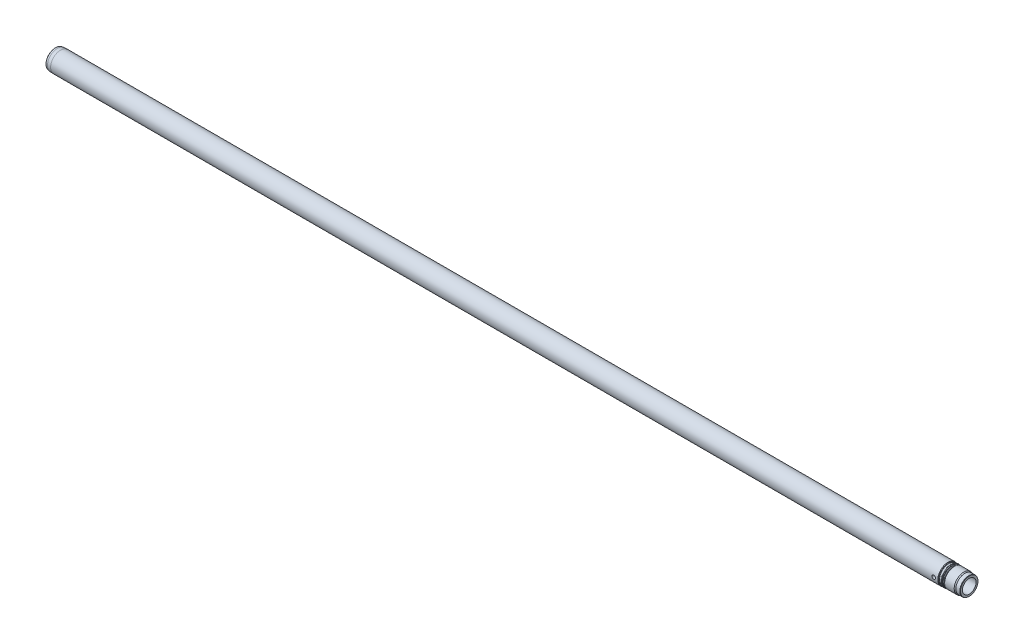
from build123d import *

# Parameters (mm, degrees)
SKETCH2_R          = 4.5
CUT_EXTRUDE1_DEPTH = 50


with BuildPart() as part:
    # Sketch1 → Base-Revolve (revolve)
    with BuildSketch(Plane.XY):
        with BuildLine():
            Line((0, 21), (0, 23.5))
            Line((0, 23.5), (0.5, 24))
            Line((0.5, 24), (5, 24))
            Line((5, 24), (5, 24.75))
            Line((5, 24.75), (13, 24.75))
            Line((13, 24.75), (13, 25))
            Line((13, 25), (2230.5, 25))
            Line((2230.5, 25), (2232, 24.133974596))
            Line((2232, 24.133974596), (2232, 23.8))
            ThreePointArc((2232, 23.8), (2232.234314575, 23.234314575), (2232.8, 23))
            Line((2232.8, 23), (2237.2, 23))
            ThreePointArc((2237.2, 23), (2237.765685425, 23.234314575), (2238, 23.8))
            Line((2238, 23.8), (2238, 24.25))
            ThreePointArc((2238, 24.25), (2238.146446609, 24.603553391), (2238.5, 24.75))
            Line((2238.5, 24.75), (2239.5, 24.75))
            Line((2239.5, 24.75), (2241, 23.883974596))
            Line((2241, 23.883974596), (2241, 23.55))
            ThreePointArc((2241, 23.55), (2241.234314575, 22.984314575), (2241.8, 22.75))
            Line((2241.8, 22.75), (2244, 22.75))
            Line((2244, 22.75), (2246.453263132, 24))
            Line((2246.453263132, 24), (2270.401923789, 24))
            Line((2270.401923789, 24), (2273, 22.5))
            Line((2273, 22.5), (2283, 22.5))
            Line((2283, 22.5), (2284, 21.922649731))
            Line((2284, 21.922649731), (2284, 17))
            Line((2284, 17), (6.92820323, 17))
            Line((6.92820323, 17), (0, 21))
        make_face()
    revolve(axis=Axis((0, 0, 0), (1, 0, 0)))

    # Sketch2 → Cut-Extrude1 (cut, symmetric)
    with BuildSketch(Plane.XY):
        with Locations((2220, 0)):
            Circle(SKETCH2_R)
    extrude(amount=CUT_EXTRUDE1_DEPTH, both=True, mode=Mode.SUBTRACT)


solid = part.part
